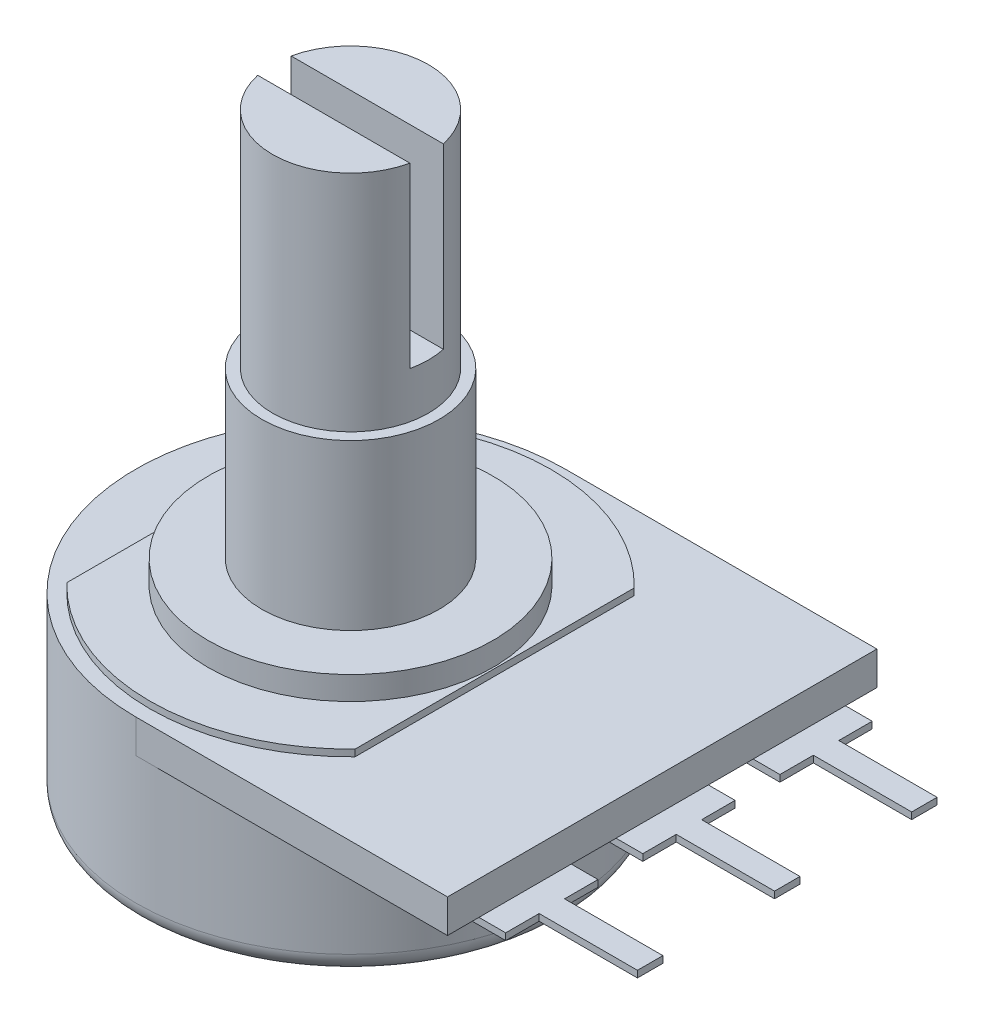
from build123d import *

# Parameters (mm, degrees)
SKETCH1_R           = 8.1534
BOSS_EXTRUDE1_DEPTH = 5.6134
BOSS_EXTRUDE2_DEPTH = 1.27
BOSS_EXTRUDE3_DEPTH = 0.254
SKETCH4_R           = 5.4102
BOSS_EXTRUDE4_DEPTH = 0.889
SKETCH5_R           = 3.3655
BOSS_EXTRUDE5_DEPTH = 6.2484
SKETCH6_R           = 2.9591
BOSS_EXTRUDE6_DEPTH = 8.509
SKETCH7_W           = 8.77263503
SKETCH7_H           = 1.27
CUT_EXTRUDE1_DEPTH  = 6.7564
BOSS_EXTRUDE7_DEPTH = 0.254
LPATTERN1_COUNT     = 2
LPATTERN1_PITCH     = 5.207
LPATTERN2_COUNT     = 2
LPATTERN2_PITCH     = 5.207
FILLET1_R           = 0.762


with BuildPart() as part:
    # Sketch1 → Boss-Extrude1 (new body)
    with BuildSketch(Plane(origin=(0, 0, 0), x_dir=(1, 0, 0), z_dir=(0, 1, 0))):
        Circle(SKETCH1_R)
    extrude(amount=BOSS_EXTRUDE1_DEPTH)

    # Sketch2 → Boss-Extrude2 (add)
    with BuildSketch(Plane(origin=(0, 5.6134, 0), x_dir=(1, 0, 0), z_dir=(0, 1, 0))):
        with BuildLine():
            Line((0, 8.1534), (11.8364, 8.1534))
            Line((11.8364, 8.1534), (11.8364, -8.1534))
            Line((11.8364, -8.1534), (0, -8.1534))
            ThreePointArc((0, -8.1534), (-8.1534, 0), (0, 8.1534))
        make_face()
    extrude(amount=BOSS_EXTRUDE2_DEPTH)

    # Sketch3 → Boss-Extrude3 (add)
    with BuildSketch(Plane(origin=(0, 6.8834, 0), x_dir=(1, 0, 0), z_dir=(0, 1, 0))):
        with BuildLine():
            Line((-5.4737, 5.301227057), (-5.4737, -5.301227057))
            ThreePointArc((-5.4737, -5.301227057), (0, -7.62), (5.4737, -5.301227057))
            Line((5.4737, -5.301227057), (5.4737, 5.301227057))
            ThreePointArc((5.4737, 5.301227057), (0, 7.62), (-5.4737, 5.301227057))
        make_face()
    extrude(amount=BOSS_EXTRUDE3_DEPTH)

    # Sketch4 → Boss-Extrude4 (add)
    with BuildSketch(Plane(origin=(0, 7.1374, 0), x_dir=(1, 0, 0), z_dir=(0, 1, 0))):
        Circle(SKETCH4_R)
    extrude(amount=BOSS_EXTRUDE4_DEPTH)

    # Sketch5 → Boss-Extrude5 (add)
    with BuildSketch(Plane(origin=(0, 8.0264, 0), x_dir=(1, 0, 0), z_dir=(0, 1, 0))):
        Circle(SKETCH5_R)
    extrude(amount=BOSS_EXTRUDE5_DEPTH)

    # Sketch6 → Boss-Extrude6 (add)
    with BuildSketch(Plane(origin=(0, 14.2748, 0), x_dir=(1, 0, 0), z_dir=(0, 1, 0))):
        Circle(SKETCH6_R)
    extrude(amount=BOSS_EXTRUDE6_DEPTH)

    # Sketch7 → Cut-Extrude1 (cut)
    with BuildSketch(Plane(origin=(0, 22.7838, 0), x_dir=(1, 0, 0), z_dir=(0, 1, 0))):
        Rectangle(SKETCH7_W, SKETCH7_H)
    extrude(amount=-CUT_EXTRUDE1_DEPTH, mode=Mode.SUBTRACT)

    # Sketch8 → Boss-Extrude7 (add)
    with BuildSketch(Plane.XZ.offset(-5.6134)):
        Polygon((8.350699667, 1.7526), (12.8524, 1.7526), (12.8524, 0.4826), (16.5862, 0.4826), (16.5862, -0.4826), (12.8524, -0.4826), (12.8524, -1.7526), (8.350699667, -1.7526), align=None)
    boss_extrude7 = extrude(amount=BOSS_EXTRUDE7_DEPTH)

    # LPattern1: Boss-Extrude7 ×2
    with Locations(*[(0, 0, -i * LPATTERN1_PITCH) for i in range(1, LPATTERN1_COUNT)]):
        add(boss_extrude7)

    # LPattern2: Boss-Extrude7 ×2
    with Locations(*[(0, 0, i * LPATTERN2_PITCH) for i in range(1, LPATTERN2_COUNT)]):
        add(boss_extrude7)

    # Fillet1
    fillet1_edges = [part.edges().sort_by_distance(p)[0] for p in [
        (-8.1534, 0, 0),
    ]]
    fillet(fillet1_edges, radius=FILLET1_R)


solid = part.part
